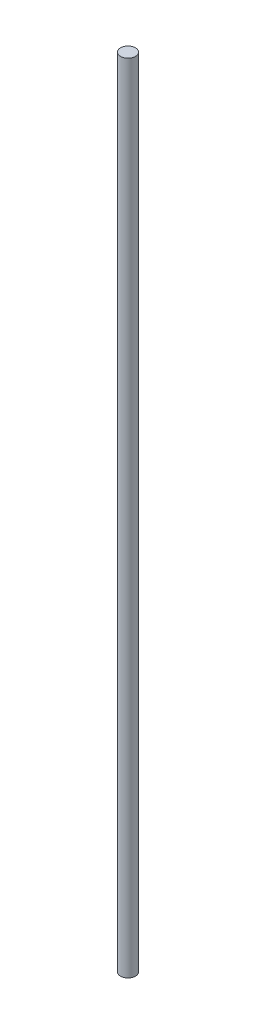
from build123d import *

# Parameters (mm, degrees)
SKETCH1_R           = 2.38125
BOSS_EXTRUDE1_DEPTH = 254


with BuildPart() as part:
    # Sketch1 → Boss-Extrude1 (new body)
    with BuildSketch(Plane(origin=(0, 0, 0), x_dir=(1, 0, 0), z_dir=(0, 1, 0))):
        Circle(SKETCH1_R)
    extrude(amount=BOSS_EXTRUDE1_DEPTH)


solid = part.part
